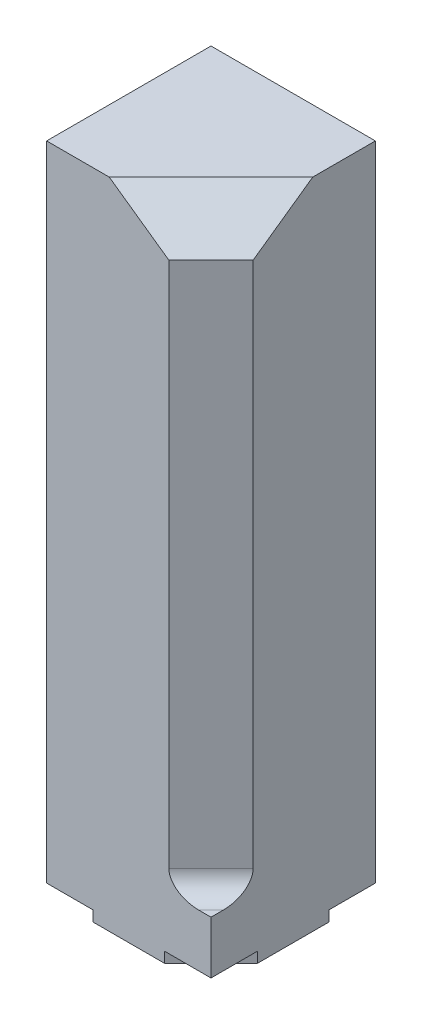
from build123d import *

# Parameters (mm, degrees)
SKETCH1_W           = 3.9
SKETCH1_H           = 3.9
BOSS_EXTRUDE1_DEPTH = 15.5
SKETCH3_W           = 2
SKETCH3_H           = 14
CUT_EXTRUDE1_DEPTH  = 17.22867832
SKETCH4_W           = 3.4
SKETCH4_H           = 3.4
CUT_EXTRUDE2_DEPTH  = 0.25
CUT_EXTRUDE3_DEPTH  = 0.25
CHAMFER1_SIZE       = 1
FILLET1_R           = 0.5


with BuildPart() as part:
    # Sketch1 → Boss-Extrude1 (new body)
    with BuildSketch(Plane(origin=(0, 0, 0), x_dir=(1, 0, 0), z_dir=(0, 1, 0))):
        Rectangle(SKETCH1_W, SKETCH1_H)
    extrude(amount=BOSS_EXTRUDE1_DEPTH)

    # Sketch3 → Cut-Extrude1 (cut, through all)
    with BuildSketch(Plane(origin=(1.45, 0, 1.45), x_dir=(0.7071067811865475, 0, -0.7071067811865476), z_dir=(0.7071067811865476, 0, 0.7071067811865475))):
        with Locations((0, 8.5)):
            Rectangle(SKETCH3_W, SKETCH3_H)
    extrude(amount=CUT_EXTRUDE1_DEPTH, mode=Mode.SUBTRACT)

    # Sketch4 → Cut-Extrude2 (cut)
    with BuildSketch(Plane.XZ):
        Rectangle(SKETCH4_W, SKETCH4_H)
    extrude(amount=-CUT_EXTRUDE2_DEPTH, mode=Mode.SUBTRACT)

    # Sketch5 → Cut-Extrude3 (cut)
    with BuildSketch(Plane.XZ):
        Polygon((1.95, 1.95), (0.85, 1.95), (1.95, 0.85), align=None)
        Polygon((1.95, -1.95), (1.95, -0.85), (0.85, -1.95), align=None)
        Polygon((-1.95, 1.95), (-0.85, 1.95), (-1.95, 0.85), align=None)
        Polygon((-1.95, -1.95), (-0.85, -1.95), (-1.95, -0.85), align=None)
    extrude(amount=-CUT_EXTRUDE3_DEPTH, mode=Mode.SUBTRACT)

    # Chamfer1
    chamfer1_edges = [part.edges().sort_by_distance(p)[0] for p in [
        (1.45, 15.5, 1.45),
    ]]
    chamfer(chamfer1_edges, length=CHAMFER1_SIZE)

    # Fillet1
    fillet1_edges = [part.edges().sort_by_distance(p)[0] for p in [
        (1.45, 1.5, 1.45),
    ]]
    fillet(fillet1_edges, radius=FILLET1_R)


solid = part.part
